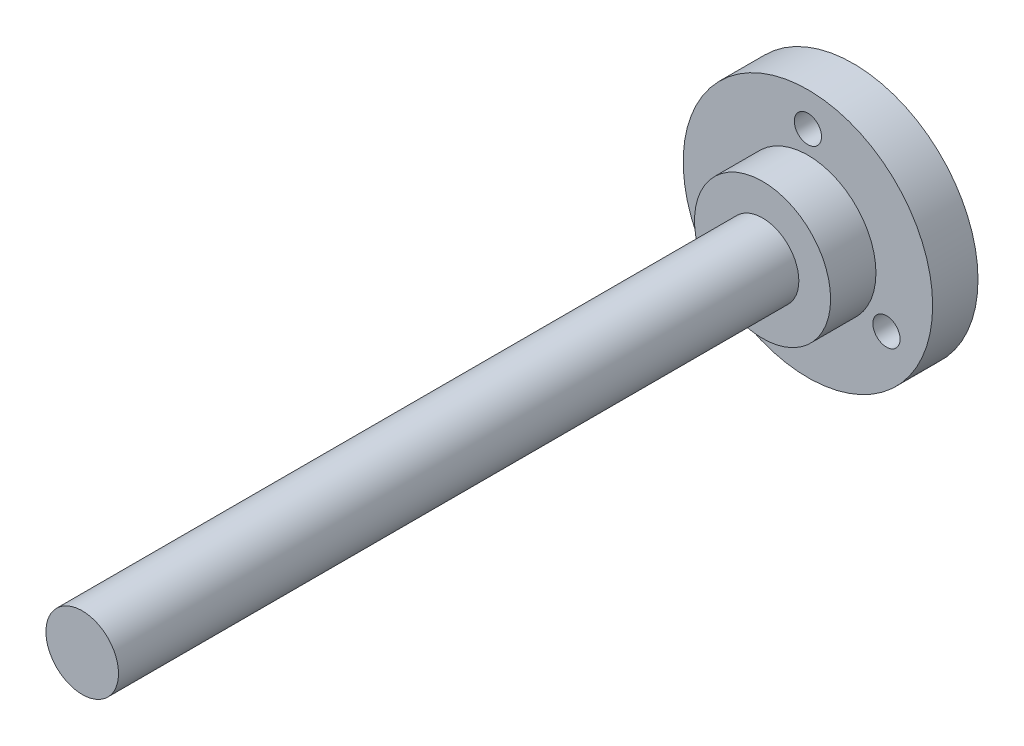
from build123d import *

# Parameters (mm, degrees)
SKETCH1_R           = 27.5
SKETCH1_R_2         = 3
BOSS_EXTRUDE1_DEPTH = 10
SKETCH2_R           = 15
BOSS_EXTRUDE2_DEPTH = 10
SKETCH3_R           = 8
BOSS_EXTRUDE3_DEPTH = 150


with BuildPart() as part:
    # Sketch1 → Boss-Extrude1 (new body)
    with BuildSketch(Plane.XY):
        Circle(SKETCH1_R)
        with Locations((0, 20)):
            Circle(SKETCH1_R_2, mode=Mode.SUBTRACT)
        with Locations((17.320508076, -10)):
            Circle(SKETCH1_R_2, mode=Mode.SUBTRACT)
        with Locations((-17.320508076, -10)):
            Circle(SKETCH1_R_2, mode=Mode.SUBTRACT)
    extrude(amount=BOSS_EXTRUDE1_DEPTH)

    # Sketch2 → Boss-Extrude2 (add)
    with BuildSketch(Plane.XY.offset(10)):
        Circle(SKETCH2_R)
    extrude(amount=BOSS_EXTRUDE2_DEPTH)

    # Sketch3 → Boss-Extrude3 (add)
    with BuildSketch(Plane.XY.offset(20)):
        Circle(SKETCH3_R)
    extrude(amount=BOSS_EXTRUDE3_DEPTH)


solid = part.part
